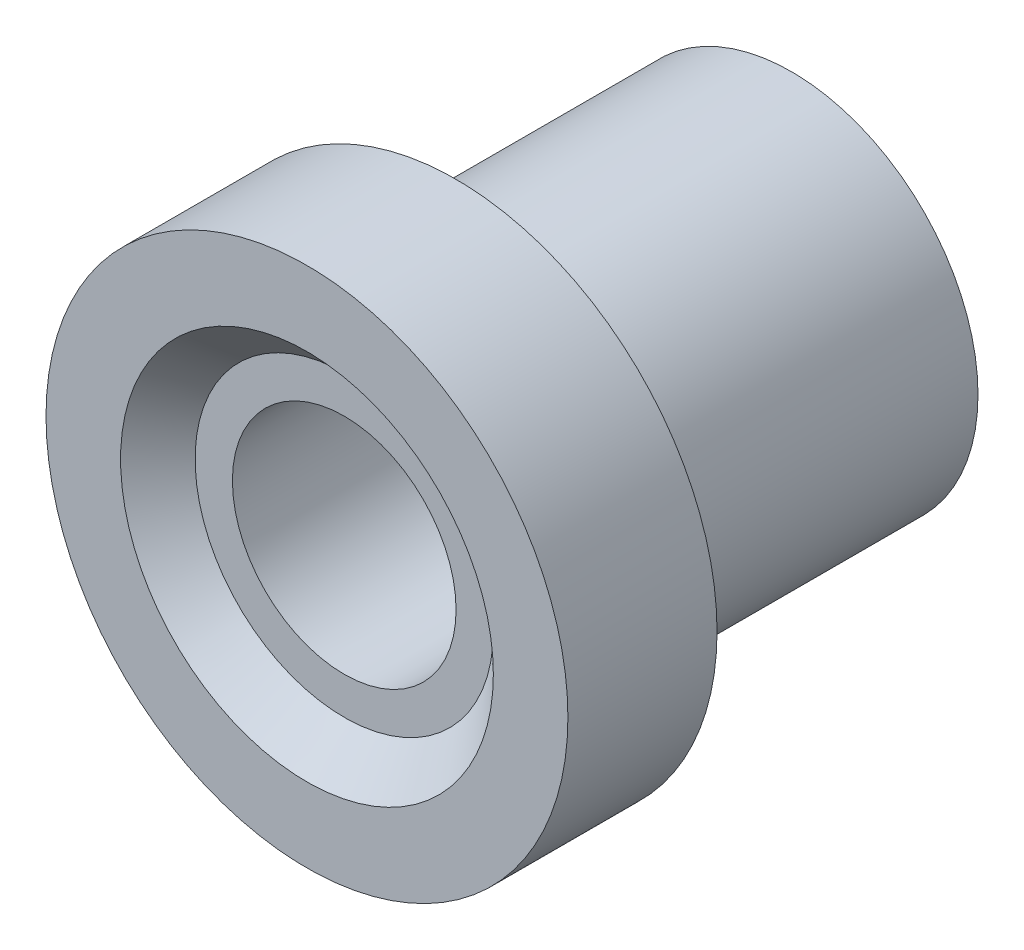
from build123d import *


with BuildPart() as part:
    # Эскиз1 → Повернуть1 (revolve)
    with BuildSketch(Plane(origin=(0, 0, 0), x_dir=(0, 0, -1), z_dir=(1, 0, 0))):
        Polygon((-4, 7), (-4, 5), (-3, 4), (-3, 3), (9, 2.998099963), (9, 5), (0, 5), (0, 7), align=None)
    revolve(axis=Axis((0, 0, 1000), (0, 0, -1)))


solid = part.part
